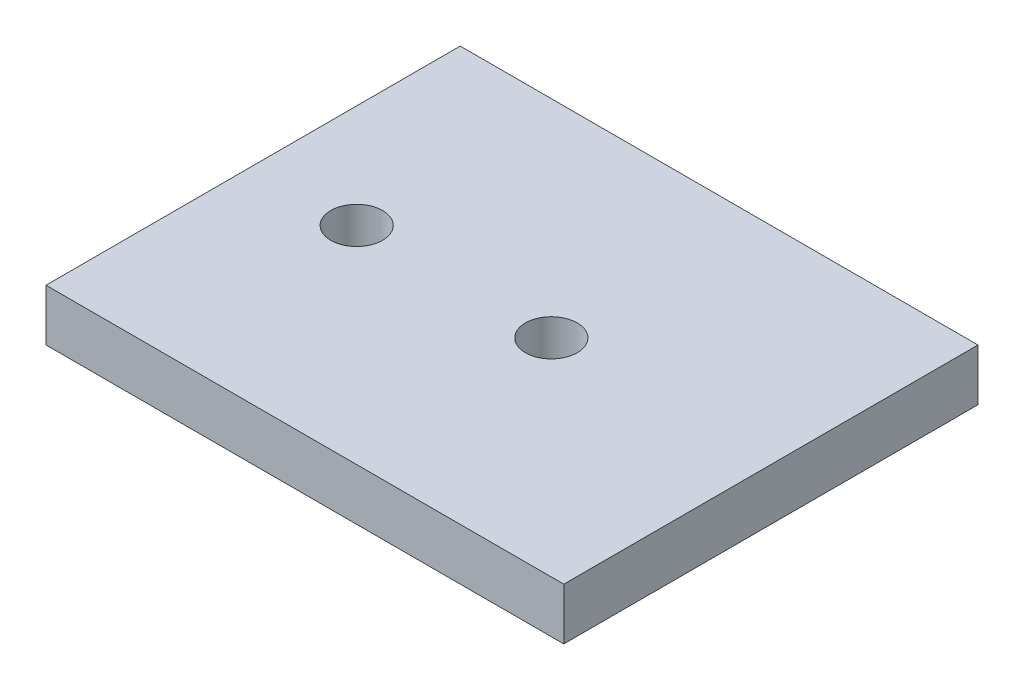
from build123d import *

# Parameters (mm, degrees)
SKETCH1_W           = 127
SKETCH1_H           = 101.6
BOSS_EXTRUDE1_DEPTH = 12.7
SKETCH2_R           = 6.35
CUT_EXTRUDE1_DEPTH  = 13.7


with BuildPart() as part:
    # Sketch1 → Boss-Extrude1 (new body)
    with BuildSketch(Plane(origin=(0, 0, 0), x_dir=(1, 0, 0), z_dir=(0, 1, 0))):
        Rectangle(SKETCH1_W, SKETCH1_H)
    extrude(amount=BOSS_EXTRUDE1_DEPTH)

    # Sketch2 → Cut-Extrude1 (cut, through all)
    with BuildSketch(Plane(origin=(0, 12.7, 0), x_dir=(1, 0, 0), z_dir=(0, 1, 0))):
        with Locations((-38.1, 0)):
            Circle(SKETCH2_R)
        with Locations((9.652, 0)):
            Circle(SKETCH2_R)
    extrude(amount=-CUT_EXTRUDE1_DEPTH, mode=Mode.SUBTRACT)


solid = part.part
